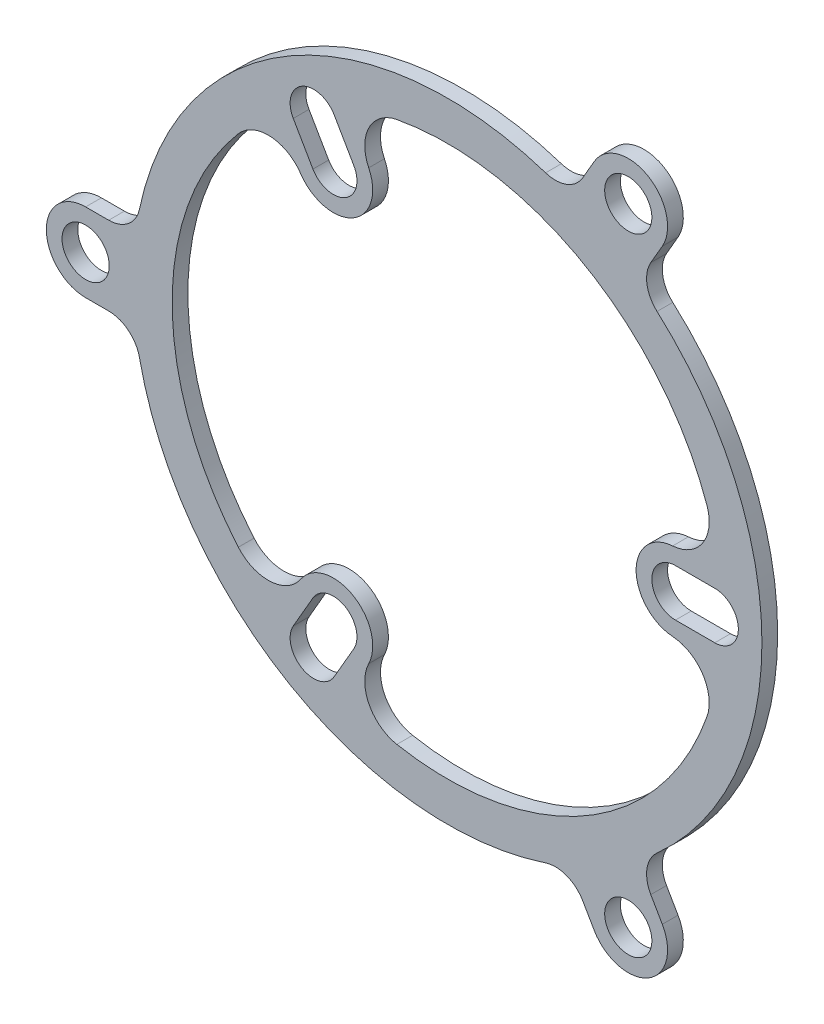
from build123d import *

# Parameters (mm, degrees)
SKETCH1_R                = 40
SKETCH1_R_2              = 35
BOSS_EXTRUDE1_DEPTH      = 2
BOSS_EXTRUDE2_DEPTH      = 2
SKETCH3_R                = 3
CUT_EXTRUDE1_DEPTH       = 2
FILLET1_R                = 5
CIRPATTERN1_COUNT        = 3
FILLET1_OF_CIRPATTERN1_R = 5
SKETCH4_R                = 3
BOSS_EXTRUDE3_DEPTH      = 2
FILLET2_R                = 4
CIRPATTERN2_COUNT        = 3
FILLET2_OF_CIRPATTERN2_R = 4


with BuildPart() as part:
    # Sketch1 → Boss-Extrude1 (new body)
    with BuildSketch(Plane.XY):
        Circle(SKETCH1_R)
        Circle(SKETCH1_R_2, mode=Mode.SUBTRACT)
    extrude(amount=BOSS_EXTRUDE1_DEPTH)

    # Sketch2 → Boss-Extrude2 (add)
    with BuildSketch(Plane(origin=(0, 0, 0), x_dir=(-1, 0, 0), z_dir=(0, 0, -1))):
        with BuildLine():
            Line((-29, -5), (-34.641016151, -5))
            Line((-34.641016151, -5), (-37, -5))
            Line((-37, -5), (-37, 5))
            Line((-37, 5), (-34.641016151, 5))
            Line((-34.641016151, 5), (-29, 5))
            ThreePointArc((-29, 5), (-24, 0), (-29, -5))
        make_face()
        with BuildLine():
            Line((-34, -3), (-29, -3))
            ThreePointArc((-29, -3), (-26, 0), (-29, 3))
            Line((-29, 3), (-34, 3))
            ThreePointArc((-34, 3), (-37, 0), (-34, -3))
        make_face(mode=Mode.SUBTRACT)
    boss_extrude2 = extrude(amount=-BOSS_EXTRUDE2_DEPTH)

    # Sketch3 → Cut-Extrude1 (cut)
    with BuildSketch(Plane(origin=(0, 0, 0), x_dir=(-1, 0, 0), z_dir=(0, 0, -1))):
        with Locations((-34, 0)):
            Circle(SKETCH3_R)
    cut_extrude1 = extrude(amount=-CUT_EXTRUDE1_DEPTH, mode=Mode.SUBTRACT)

    # Fillet1
    fillet1_edges = [part.edges().sort_by_distance(p)[0] for p in [
        (34.641016151, -5, 1),
        (34.641016151, 5, 1),
    ]]
    fillet(fillet1_edges, radius=FILLET1_R)

    # CirPattern1: Boss-Extrude2, Cut-Extrude1 ×3 about axis
    cirpattern1_axis = Axis((0, 0, 0), (0, 0, 1))
    for i in range(1, CIRPATTERN1_COUNT):
        add(boss_extrude2.rotate(cirpattern1_axis, i * 360 / CIRPATTERN1_COUNT))
        add(cut_extrude1.rotate(cirpattern1_axis, i * 360 / CIRPATTERN1_COUNT), mode=Mode.SUBTRACT)

    # Fillet1 of CirPattern1
    fillet1_of_cirpattern1_edges = [part.edges().sort_by_distance(p)[0] for p in [
        (-12.990381057, 32.5, 1),
        (-21.650635095, 27.5, 1),
        (-21.650635095, -27.5, 1),
        (-12.990381057, -32.5, 1),
    ]]
    fillet(fillet1_of_cirpattern1_edges, radius=FILLET1_OF_CIRPATTERN1_R)

    # Sketch4 → Boss-Extrude3 (add)
    with BuildSketch(Plane(origin=(0, 0, 0), x_dir=(-1, 0, 0), z_dir=(0, 0, -1))):
        with BuildLine():
            Line((-15.513007814, 36.869317712), (-18.669872981, 42.337168574))
            ThreePointArc((-18.669872981, 42.337168574), (-25.5, 44.167295593), (-27.330127019, 37.337168574))
            Line((-27.330127019, 37.337168574), (-24.173261852, 31.869317712))
            Line((-24.173261852, 31.869317712), (-15.513007814, 36.869317712))
        make_face()
        with Locations((-23, 39.837168574)):
            Circle(SKETCH4_R, mode=Mode.SUBTRACT)
    boss_extrude3 = extrude(amount=-BOSS_EXTRUDE3_DEPTH)

    # Fillet2
    fillet2_edges = [part.edges().sort_by_distance(p)[0] for p in [
        (15.513007814, 36.869317712, 1),
        (24.173261852, 31.869317712, 1),
    ]]
    fillet(fillet2_edges, radius=FILLET2_R)

    # CirPattern2: Boss-Extrude3 ×3 about axis
    cirpattern2_axis = Axis((0, 0, 0), (0, 0, 1))
    for i in range(1, CIRPATTERN2_COUNT):
        add(boss_extrude3.rotate(cirpattern2_axis, i * 360 / CIRPATTERN2_COUNT))

    # Fillet2 of CirPattern2
    fillet2_of_cirpattern2_edges = [part.edges().sort_by_distance(p)[0] for p in [
        (-39.686269666, -5, 1),
        (-39.686269666, 5, 1),
        (24.173261852, -31.869317712, 1),
        (15.513007814, -36.869317712, 1),
    ]]
    fillet(fillet2_of_cirpattern2_edges, radius=FILLET2_OF_CIRPATTERN2_R)


solid = part.part
